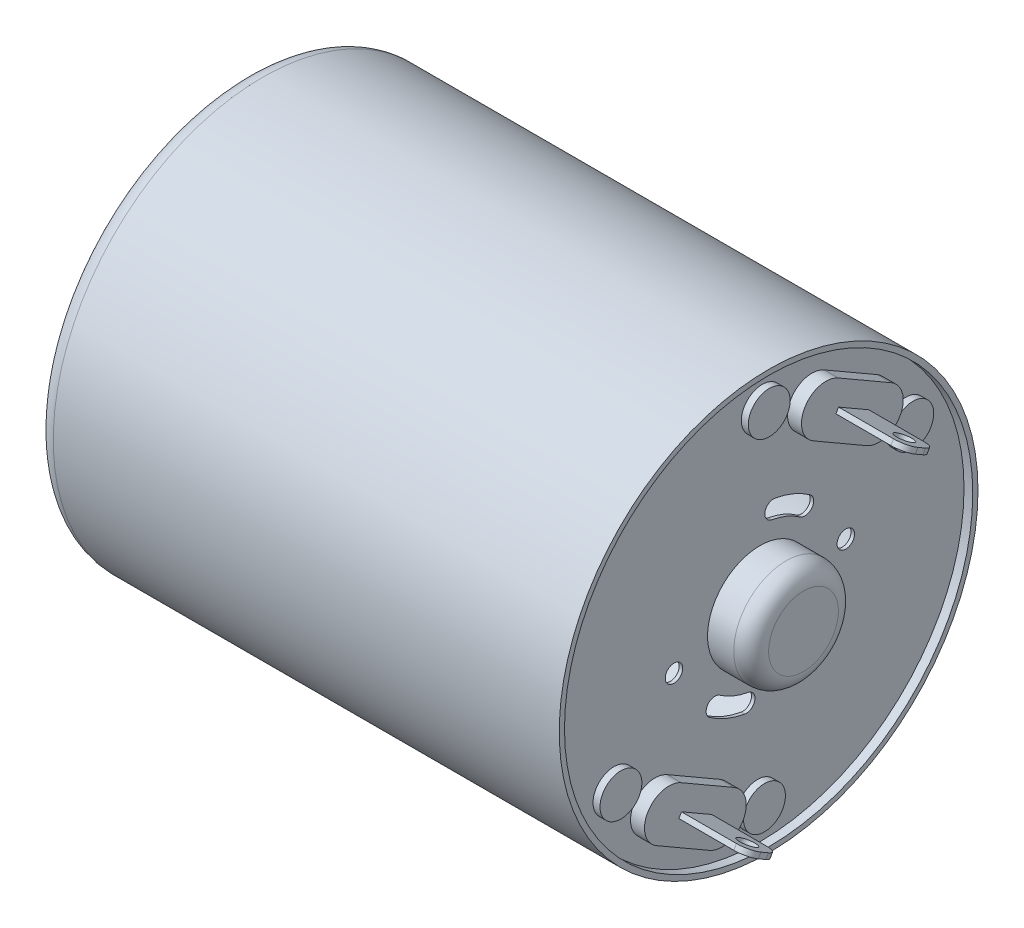
from build123d import *

# Parameters (mm, degrees)
SKETCH1_R                = 12
SKETCH1_R_2              = 11.7
BOSS_EXTRUDE1_DEPTH      = 30
SKETCH2_R                = 11.7
BOSS_EXTRUDE2_DEPTH      = 0.2
SKETCH3_R                = 3
BOSS_EXTRUDE3_DEPTH      = 2.5
FILLET1_R                = 1
CUT_EXTRUDE1_DEPTH       = 30.5
CIRPATTERN1_COUNT        = 2
SKETCH5_R                = 0.5
CUT_EXTRUDE2_DEPTH       = 30.5
CIRPATTERN2_COUNT        = 2
SKETCH7_R                = 11.7
BOSS_EXTRUDE4_DEPTH      = 0.3
CUT_EXTRUDE3_REACH       = 34
SKETCH9_R                = 3
BOSS_EXTRUDE5_DEPTH      = 0.8
SKETCH10_R               = 1.2
BOSS_EXTRUDE6_DEPTH      = 0.4
BOSS_EXTRUDE7_DEPTH      = 3.9
SKETCH12_R               = 0.5
CUT_EXTRUDE4_DEPTH       = 8.542304845
FILLET3_R                = 0.75
CIRPATTERN3_COUNT        = 2
FILLET3_OF_CIRPATTERN3_R = 0.75
SKETCH13_R               = 3
BOSS_EXTRUDE8_DEPTH      = 0.3
SKETCH14_R               = 1
CUT_EXTRUDE5_DEPTH       = 0.3
FILLET2_R                = 1
CIRPATTERN4_COUNT        = 2


with BuildPart() as part:
    # Sketch1 → Boss-Extrude1 (new body)
    with BuildSketch(Plane(origin=(0, 0, 0), x_dir=(0, 0, -1), z_dir=(1, 0, 0))):
        Circle(SKETCH1_R)
        Circle(SKETCH1_R_2, mode=Mode.SUBTRACT)
    extrude(amount=-BOSS_EXTRUDE1_DEPTH)

    # Sketch2 → Boss-Extrude2 (add)
    with BuildSketch(Plane(origin=(-0.5, 0, 0), x_dir=(0, 0, -1), z_dir=(1, 0, 0))):
        Circle(SKETCH2_R)
    extrude(amount=-BOSS_EXTRUDE2_DEPTH)

    # Sketch3 → Boss-Extrude3 (add)
    with BuildSketch(Plane(origin=(-0.5, 0, 0), x_dir=(0, 0, -1), z_dir=(1, 0, 0))):
        Circle(SKETCH3_R)
    extrude(amount=BOSS_EXTRUDE3_DEPTH)

    # Fillet1
    fillet1_edges = [part.edges().sort_by_distance(p)[0] for p in [
        (2, 0, 3),
    ]]
    fillet(fillet1_edges, radius=FILLET1_R)

    # Sketch4 → Cut-Extrude1 (cut, through all)
    with BuildSketch(Plane(origin=(-0.5, 0, 0), x_dir=(0, 0, -1), z_dir=(1, 0, 0))):
        with BuildLine():
            ThreePointArc((2.867882182, 4.095760221), (1.913417162, 4.619397663), (0.868240888, 4.924038765))
            ThreePointArc((0.868240888, 4.924038765), (0.289012923, 4.518458977), (0.694592711, 3.939231012))
            ThreePointArc((0.694592711, 3.939231012), (1.530733729, 3.69551813), (2.294305745, 3.276608177))
            ThreePointArc((2.294305745, 3.276608177), (2.990669986, 3.399395981), (2.867882182, 4.095760221))
        make_face()
    cut_extrude1 = extrude(amount=-CUT_EXTRUDE1_DEPTH, mode=Mode.SUBTRACT)

    # CirPattern1: Cut-Extrude1 ×2 about axis
    cirpattern1_axis = Axis((0, 0, 0), (1, 0, 0))
    for i in range(1, CIRPATTERN1_COUNT):
        add(cut_extrude1.rotate(cirpattern1_axis, i * 360 / CIRPATTERN1_COUNT), mode=Mode.SUBTRACT)

    # Sketch5 → Cut-Extrude2 (cut, through all)
    with BuildSketch(Plane(origin=(-0.5, 0, 0), x_dir=(0, 0, -1), z_dir=(1, 0, 0))):
        with Locations((4.924038765, 0.868240888)):
            Circle(SKETCH5_R)
    cut_extrude2 = extrude(amount=-CUT_EXTRUDE2_DEPTH, mode=Mode.SUBTRACT)

    # CirPattern2: Cut-Extrude2 ×2 about axis
    cirpattern2_axis = Axis((0, 0, 0), (1, 0, 0))
    for i in range(1, CIRPATTERN2_COUNT):
        add(cut_extrude2.rotate(cirpattern2_axis, i * 360 / CIRPATTERN2_COUNT), mode=Mode.SUBTRACT)

    # Sketch7 → Boss-Extrude4 (add)
    with BuildSketch(Plane.ZY.offset(30)):
        Circle(SKETCH7_R)
    extrude(amount=-BOSS_EXTRUDE4_DEPTH)

    # Sketch9 → Cut-Extrude3 (cut, up to next)
    with BuildSketch(Plane.ZY.offset(30), mode=Mode.PRIVATE) as cut_extrude3_sk1:
        Circle(SKETCH9_R)
    cut_extrude3_tool1 = extrude(cut_extrude3_sk1.sketch, amount=-CUT_EXTRUDE3_REACH, mode=Mode.PRIVATE) & part.part
    add(cut_extrude3_tool1.solids().sort_by_distance((-30, 0, 0))[0], mode=Mode.SUBTRACT)

    # Sketch6 → Boss-Extrude5 (add)
    with BuildSketch(Plane(origin=(-0.5, 0, 0), x_dir=(0, 0, -1), z_dir=(1, 0, 0))):
        with BuildLine():
            Line((3.684455543, 9.881664199), (6.715544457, 8.131664199))
            ThreePointArc((6.715544457, 8.131664199), (7.227980022, 6.219228634), (5.315544457, 5.706793069))
            Line((5.315544457, 5.706793069), (2.284455543, 7.456793069))
            ThreePointArc((2.284455543, 7.456793069), (1.772019978, 9.369228634), (3.684455543, 9.881664199))
        make_face()
    boss_extrude5 = extrude(amount=BOSS_EXTRUDE5_DEPTH)

    # Sketch10 → Boss-Extrude6 (add)
    with BuildSketch(Plane(origin=(-0.5, 0, 0), x_dir=(0, 0, -1), z_dir=(1, 0, 0))):
        with Locations((0.136379332, 9.736215932)):
            Circle(SKETCH10_R)
        with Locations((8.363620668, 4.986215932)):
            Circle(SKETCH10_R)
    boss_extrude6 = extrude(amount=BOSS_EXTRUDE6_DEPTH)

    # Sketch11 → Boss-Extrude7 (add)
    with BuildSketch(Plane(origin=(0.3, 0, 0), x_dir=(0, 0, -1), z_dir=(1, 0, 0))):
        Polygon((3.708974596, 8.424132445), (5.441025404, 7.424132445), (5.291025404, 7.164324823), (3.558974596, 8.164324823), align=None)
    boss_extrude7 = extrude(amount=BOSS_EXTRUDE7_DEPTH)

    # Sketch12 → Cut-Extrude4 (cut, through all)
    with BuildSketch(Plane(origin=(0, 7.664324823, -4.425), x_dir=(-1, 0, 0), z_dir=(0, -0.866025404, 0.5))):
        with Locations((-3.2, 0)):
            Circle(SKETCH12_R)
    cut_extrude4 = extrude(amount=-CUT_EXTRUDE4_DEPTH, mode=Mode.SUBTRACT)

    # Fillet3
    fillet3_edges = [part.edges().sort_by_distance(p)[0] for p in [
        (4.2, 7.294228634, -5.366025404),
        (4.2, 8.294228634, -3.633974596),
    ]]
    fillet(fillet3_edges, radius=FILLET3_R)

    # CirPattern3: Boss-Extrude5, Boss-Extrude7, Cut-Extrude4 ×2 about axis
    cirpattern3_axis = Axis((0, 0, 0), (1, 0, 0))
    for i in range(1, CIRPATTERN3_COUNT):
        add(boss_extrude5.rotate(cirpattern3_axis, i * 360 / CIRPATTERN3_COUNT))
        add(boss_extrude7.rotate(cirpattern3_axis, i * 360 / CIRPATTERN3_COUNT))
        add(cut_extrude4.rotate(cirpattern3_axis, i * 360 / CIRPATTERN3_COUNT), mode=Mode.SUBTRACT)

    # Fillet3 of CirPattern3
    fillet3_of_cirpattern3_edges = [part.edges().sort_by_distance(p)[0] for p in [
        (4.2, -7.294228634, 5.366025404),
        (4.2, -8.294228634, 3.633974596),
    ]]
    fillet(fillet3_of_cirpattern3_edges, radius=FILLET3_OF_CIRPATTERN3_R)

    # Fillet2
    fillet2_edges = [part.edges().sort_by_distance(p)[0] for p in [
        (-30, 0, 12),
    ]]
    fillet(fillet2_edges, radius=FILLET2_R)

    # CirPattern4: Boss-Extrude6 ×2 about axis
    cirpattern4_axis = Axis((0, 0, 0), (1, 0, 0))
    for i in range(1, CIRPATTERN4_COUNT):
        add(boss_extrude6.rotate(cirpattern4_axis, i * 360 / CIRPATTERN4_COUNT))


with BuildPart() as body_2:
    # Sketch13 → Boss-Extrude8 (new body)
    with BuildSketch(Plane.ZY.offset(30)):
        Circle(SKETCH13_R)
    extrude(amount=-BOSS_EXTRUDE8_DEPTH)

    # Sketch14 → Cut-Extrude5 (cut)
    with BuildSketch(Plane.ZY.offset(30)):
        Circle(SKETCH14_R)
    extrude(amount=-CUT_EXTRUDE5_DEPTH, mode=Mode.SUBTRACT)


solid = Compound([part.part, body_2.part])
